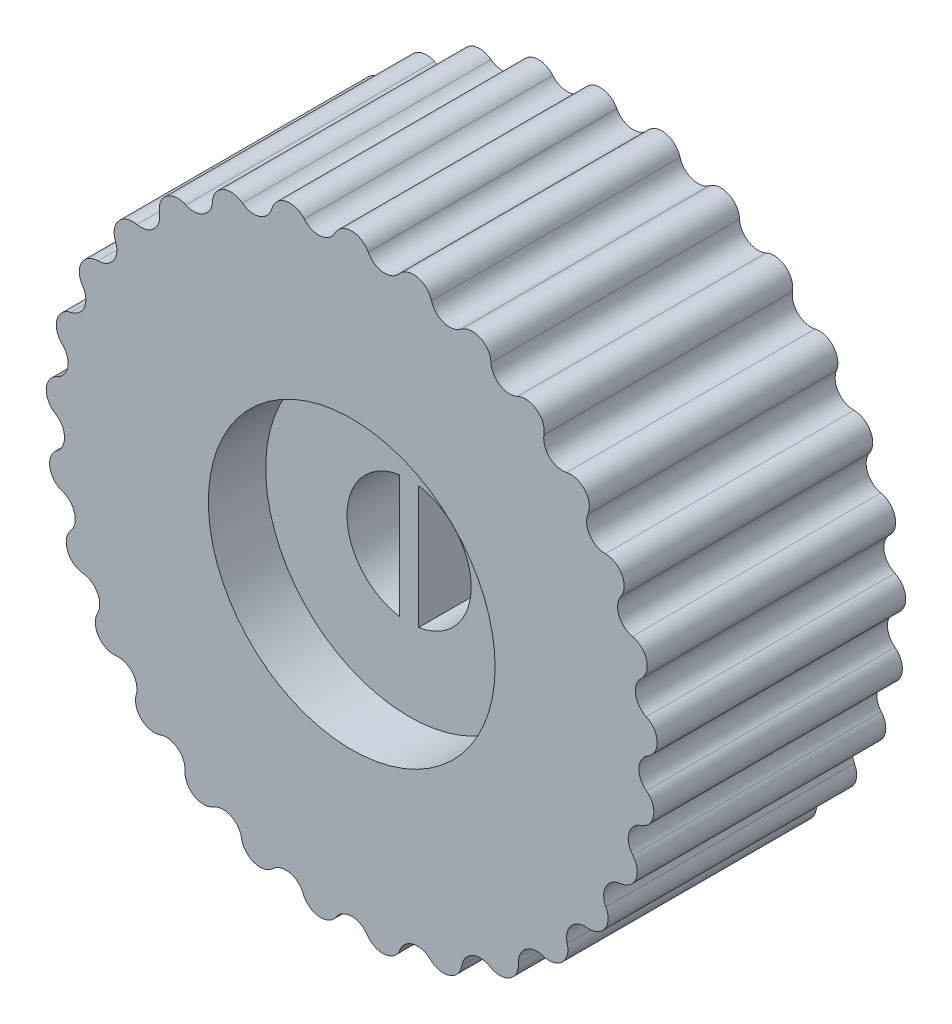
from build123d import *

# Parameters (mm, degrees)
BOSS_EXTRUDE1_DEPTH = 13
SKETCH4_R           = 3.25
CUT_EXTRUDE1_DEPTH  = 12
SKETCH5_R           = 7.5
CUT_EXTRUDE2_DEPTH  = 3
SKETCH6_W           = 1
SKETCH6_H           = 6.908542988
BOSS_EXTRUDE4_DEPTH = 9
FILLET1_R           = 1


with BuildPart() as part:
    # Sketch1 → Boss-Extrude1 (new body)
    with BuildSketch(Plane.XY):
        with BuildLine():
            ThreePointArc((-0.866208619, 15.475777287), (0, 16), (0.866208619, 15.475777287))
            ThreePointArc((0.866208619, 15.475777287), (1.626702908, 14.957286238), (2.480877513, 15.300171462))
            ThreePointArc((2.480877513, 15.300171462), (3.439527043, 15.625928891), (4.172791799, 14.927752966))
            ThreePointArc((4.172791799, 14.927752966), (4.804045905, 14.257900157), (5.71196057, 14.409146625))
            ThreePointArc((5.71196057, 14.409146625), (6.718225625, 14.521206715), (7.284259872, 13.681723507))
            ThreePointArc((7.284259872, 13.681723507), (7.756757055, 12.891830512), (8.675958699, 12.844366106))
            ThreePointArc((8.675958699, 12.844366106), (9.682787443, 12.737489051), (10.055124049, 11.795951863))
            ThreePointArc((10.055124049, 11.795951863), (10.346770866, 10.9229532), (11.234278642, 10.678997303))
            ThreePointArc((11.234278642, 10.678997303), (12.194592882, 10.358180557), (12.355821801, 9.35861462))
            ThreePointArc((12.355821801, 9.35861462), (12.452981171, 8.443330736), (13.267296201, 8.014290456))
            ThreePointArc((13.267296201, 8.014290456), (14.136192711, 7.494535051), (14.078775059, 6.483678959))
            ThreePointArc((14.078775059, 6.483678959), (13.976903916, 5.568907511), (14.679949736, 4.974844294))
            ThreePointArc((14.679949736, 4.974844294), (15.41679988, 4.280453416), (15.143420442, 3.305573676))
            ThreePointArc((15.143420442, 3.305573676), (14.847282169, 2.434088361), (15.406185137, 1.702779942))
            ThreePointArc((15.406185137, 1.702779942), (15.976534622, 0.866222537), (15.499976315, -0.027096558))
            ThreePointArc((15.499976315, -0.027096558), (15.023418009, -0.814546056), (15.412044443, -1.648904508))
            ThreePointArc((15.412044443, -1.648904508), (15.789224361, -2.588511945), (15.131770524, -3.358499787))
            ThreePointArc((15.131770524, -3.358499787), (14.49707552, -4.025093205), (14.697253681, -4.923488015))
            ThreePointArc((14.697253681, -4.923488015), (14.863627517, -5.922210485), (14.05601996, -6.532863299))
            ThreePointArc((14.05601996, -6.532863299), (13.292865893, -7.047431469), (13.295235671, -7.967854695))
            ThreePointArc((13.295235671, -7.967854695), (13.243023971, -8.978993046), (12.323025525, -9.401757384))
            ThreePointArc((12.323025525, -9.401757384), (11.46709663, -9.74023967), (11.271547218, -10.639653345))
            ThreePointArc((11.271547218, -10.639653345), (11.003191342, -11.615927871), (10.013820113, -11.831035743))
            ThreePointArc((10.013820113, -11.831035743), (9.105138673, -11.97760509), (8.720813745, -12.81395363))
            ThreePointArc((8.720813745, -12.81395363), (8.248861715, -13.709714819), (7.236379601, -13.70710802))
            ThreePointArc((7.236379601, -13.70710802), (6.317434552, -13.654911008), (5.762304713, -14.389087685))
            ThreePointArc((5.762304713, -14.389087685), (5.108824482, -15.162450739), (4.120574023, -14.94225116))
            ThreePointArc((4.120574023, -14.94225116), (3.234334213, -14.693728463), (2.534356717, -15.291403992))
            ThreePointArc((2.534356717, -15.291403992), (1.729904295, -15.906207314), (0.812094982, -15.478711243))
            ThreePointArc((0.812094982, -15.478711243), (0, -15.045483507), (-0.812094982, -15.478711243))
            ThreePointArc((-0.812094982, -15.478711243), (-1.729904295, -15.906207314), (-2.534356717, -15.291403992))
            ThreePointArc((-2.534356717, -15.291403992), (-3.234334213, -14.693728463), (-4.120574023, -14.94225116))
            ThreePointArc((-4.120574023, -14.94225116), (-5.108824482, -15.162450739), (-5.762304713, -14.389087685))
            ThreePointArc((-5.762304713, -14.389087685), (-6.317434552, -13.654911008), (-7.236379601, -13.70710802))
            ThreePointArc((-7.236379601, -13.70710802), (-8.248861715, -13.709714819), (-8.720813745, -12.81395363))
            ThreePointArc((-8.720813745, -12.81395363), (-9.105138673, -11.97760509), (-10.013820113, -11.831035743))
            ThreePointArc((-10.013820113, -11.831035743), (-11.003191342, -11.615927871), (-11.271547218, -10.639653345))
            ThreePointArc((-11.271547218, -10.639653345), (-11.46709663, -9.74023967), (-12.323025525, -9.401757384))
            ThreePointArc((-12.323025525, -9.401757384), (-13.243023971, -8.978993046), (-13.295235671, -7.967854695))
            ThreePointArc((-13.295235671, -7.967854695), (-13.292865893, -7.047431469), (-14.05601996, -6.532863299))
            ThreePointArc((-14.05601996, -6.532863299), (-14.863627517, -5.922210485), (-14.697253681, -4.923488015))
            ThreePointArc((-14.697253681, -4.923488015), (-14.49707552, -4.025093205), (-15.131770524, -3.358499787))
            ThreePointArc((-15.131770524, -3.358499787), (-15.789224361, -2.588511945), (-15.412044443, -1.648904508))
            ThreePointArc((-15.412044443, -1.648904508), (-15.023418009, -0.814546056), (-15.499976315, -0.027096558))
            ThreePointArc((-15.499976315, -0.027096558), (-15.976534622, 0.866222537), (-15.406185137, 1.702779942))
            ThreePointArc((-15.406185137, 1.702779942), (-14.847282169, 2.434088361), (-15.143420442, 3.305573676))
            ThreePointArc((-15.143420442, 3.305573676), (-15.41679988, 4.280453416), (-14.679949736, 4.974844294))
            ThreePointArc((-14.679949736, 4.974844294), (-13.976903916, 5.568907511), (-14.078775059, 6.483678959))
            ThreePointArc((-14.078775059, 6.483678959), (-14.136192711, 7.494535051), (-13.267296201, 8.014290456))
            ThreePointArc((-13.267296201, 8.014290456), (-12.452981171, 8.443330736), (-12.355821801, 9.35861462))
            ThreePointArc((-12.355821801, 9.35861462), (-12.194592882, 10.358180557), (-11.234278642, 10.678997303))
            ThreePointArc((-11.234278642, 10.678997303), (-10.346770866, 10.9229532), (-10.055124049, 11.795951863))
            ThreePointArc((-10.055124049, 11.795951863), (-9.682787443, 12.737489051), (-8.675958699, 12.844366106))
            ThreePointArc((-8.675958699, 12.844366106), (-7.756757055, 12.891830512), (-7.284259872, 13.681723507))
            ThreePointArc((-7.284259872, 13.681723507), (-6.718225625, 14.521206715), (-5.71196057, 14.409146625))
            ThreePointArc((-5.71196057, 14.409146625), (-4.804045905, 14.257900157), (-4.172791799, 14.927752966))
            ThreePointArc((-4.172791799, 14.927752966), (-3.439527043, 15.625928891), (-2.480877513, 15.300171462))
            ThreePointArc((-2.480877513, 15.300171462), (-1.626702908, 14.957286238), (-0.866208619, 15.475777287))
        make_face()
    extrude(amount=BOSS_EXTRUDE1_DEPTH)

    # Sketch4 → Cut-Extrude1 (cut)
    with BuildSketch(Plane.XY.offset(13)):
        Circle(SKETCH4_R)
    extrude(amount=-CUT_EXTRUDE1_DEPTH, mode=Mode.SUBTRACT)

    # Sketch5 → Cut-Extrude2 (cut)
    with BuildSketch(Plane.XY.offset(13)):
        Circle(SKETCH5_R)
    extrude(amount=-CUT_EXTRUDE2_DEPTH, mode=Mode.SUBTRACT)

    # Sketch6 → Boss-Extrude4 (add)
    with BuildSketch(Plane.XY.offset(1)):
        Rectangle(SKETCH6_W, SKETCH6_H)
    extrude(amount=BOSS_EXTRUDE4_DEPTH)

    # Fillet1
    fillet1_edges = [part.edges().sort_by_distance(p)[0] for p in [
        (-3.25, 0, 1),
        (3.25, 0, 1),
        (0.5, 0, 1),
        (-0.5, 0, 1),
    ]]
    fillet(fillet1_edges, radius=FILLET1_R)


solid = part.part
